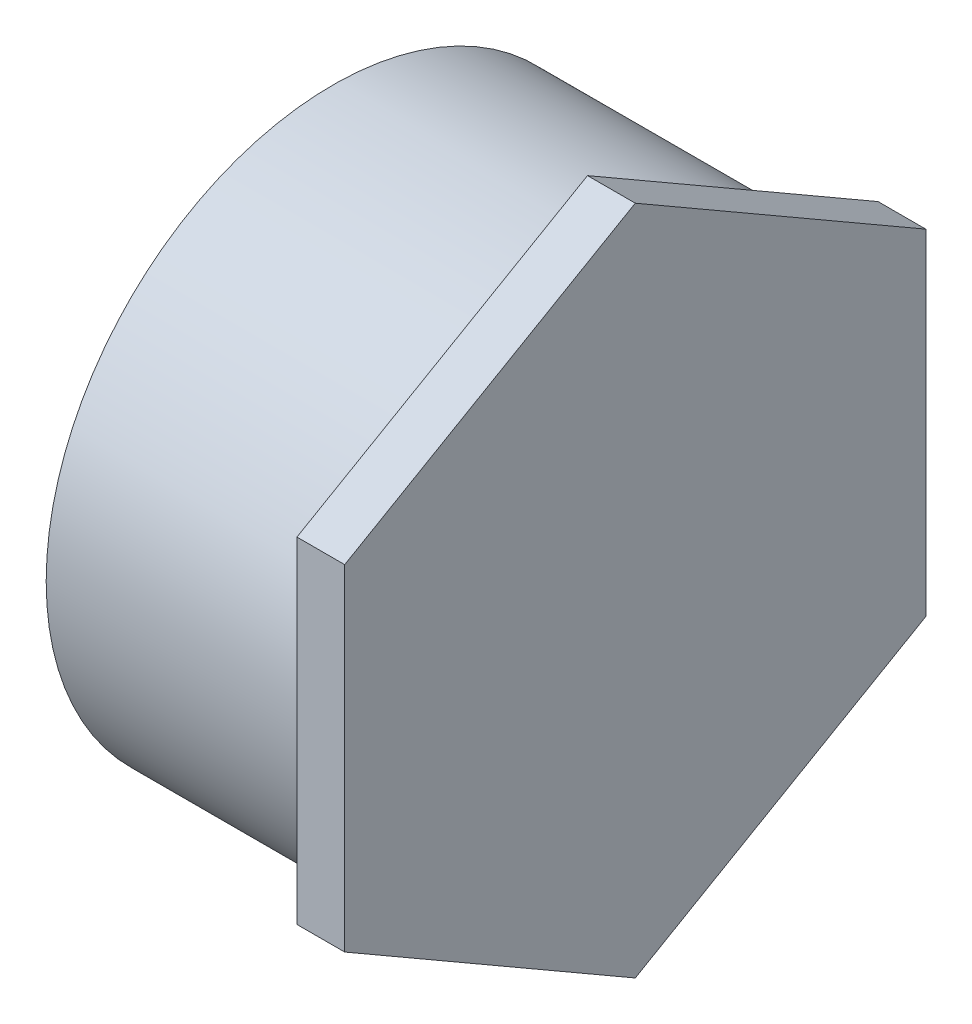
from build123d import *

# Parameters (mm, degrees)
SKETCH2_R           = 57.15
BOSS_EXTRUDE1_DEPTH = 9.525


with BuildPart() as part:
    # Sketch1 → Revolve1 (revolve)
    with BuildSketch(Plane.XY):
        Polygon((-30.1625, -57.15), (30.1625, -57.15), (30.1625, 0), (20.6375, 0), (20.6375, -51.1302), (-30.1625, -51.1302), align=None)
    revolve(axis=Axis((-30.1625, 0, 0), (1, 0, 0)))

    # Sketch2 → Boss-Extrude1 (add)
    with BuildSketch(Plane(origin=(30.1625, 0, 0), x_dir=(0, 0, -1), z_dir=(1, 0, 0))):
        Polygon((0, 66.907679321), (-57.94375, 33.45383966), (-57.94375, -33.45383966), (0, -66.907679321), (57.94375, -33.45383966), (57.94375, 33.45383966), align=None)
        Circle(SKETCH2_R, mode=Mode.SUBTRACT)
    extrude(amount=-BOSS_EXTRUDE1_DEPTH)


solid = part.part
